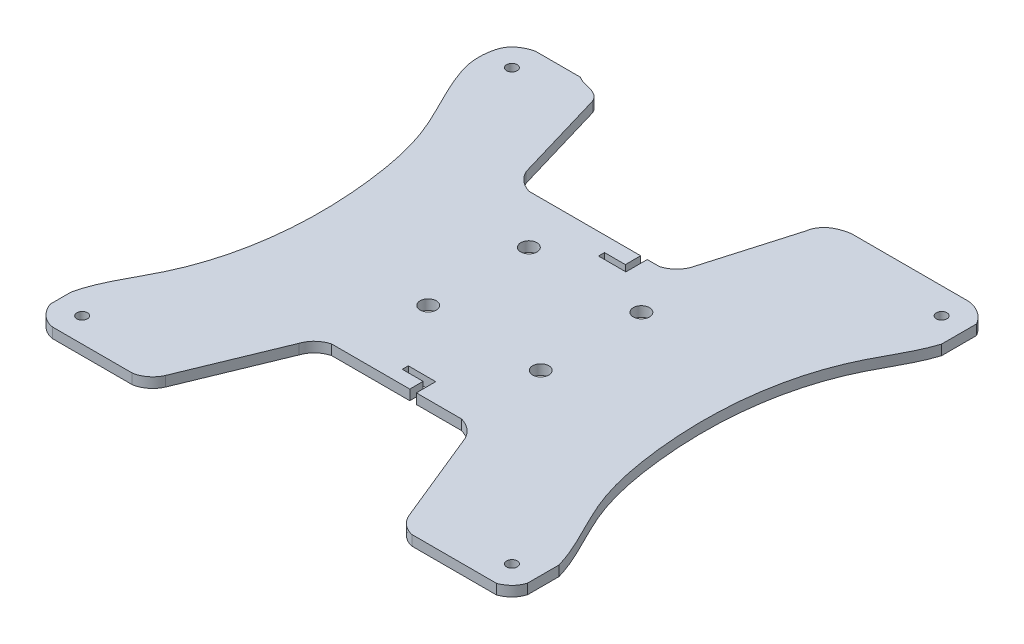
from build123d import *

# Parameters (mm, degrees)
SKETCH1_W           = 190000
SKETCH1_H           = 190000
BOSS_EXTRUDE1_DEPTH = 4000
SKETCH3_R           = 2100
SKETCH3_R_2         = 3200
CUT_EXTRUDE1_DEPTH  = 5000
CUT_EXTRUDE2_DEPTH  = 5000
CUT_EXTRUDE3_DEPTH  = 5000
CUT_EXTRUDE5_DEPTH  = 5000
CUT_EXTRUDE6_DEPTH  = 5000
CUT_EXTRUDE7_DEPTH  = 5000


with BuildPart() as part:
    # Sketch1 → Boss-Extrude1 (new body)
    with BuildSketch(Plane(origin=(0, 0, 0), x_dir=(1, 0, 0), z_dir=(0, 1, 0))):
        with Locations((210823.945907115, -88336.324664015)):
            Rectangle(SKETCH1_W, SKETCH1_H)
    extrude(amount=BOSS_EXTRUDE1_DEPTH)

    # Sketch3 → Cut-Extrude1 (cut)
    with BuildSketch(Plane(origin=(0, 4000, 0), x_dir=(1, 0, 0), z_dir=(0, 1, 0))):
        with Locations((126143.866924057, -173624.149677374)):
            Circle(SKETCH3_R)
        with Locations((126143.866924057, -3634.077007304)):
            Circle(SKETCH3_R)
        with Locations((296154.542680299, -3634.077007304)):
            Circle(SKETCH3_R)
        with Locations((296154.542680299, -173624.149677374)):
            Circle(SKETCH3_R)
        with Locations((191044.644572068, -101637.26269364)):
            Circle(SKETCH3_R_2)
        with Locations((235550.374690064, -101637.26269364)):
            Circle(SKETCH3_R_2)
        with Locations((235550.374690064, -61824.261196317)):
            Circle(SKETCH3_R_2)
        with Locations((191044.644572068, -61824.261196317)):
            Circle(SKETCH3_R_2)
    extrude(amount=-CUT_EXTRUDE1_DEPTH, mode=Mode.SUBTRACT)

    # Sketch5 → Cut-Extrude2 (cut)
    with BuildSketch(Plane(origin=(0, 4000, 0), x_dir=(1, 0, 0), z_dir=(0, 1, 0))):
        Polygon((207788.999633685, -48654.116334975), (216043.455607992, -48654.116334975), (216043.455607992, -37602.620851741), (218645.635527541, -37602.620851741), (218645.635527541, -48654.116334975), (218645.635527541, -51043.002818495), (207788.999633685, -51043.002818495), align=None)
        Polygon((207788.999633685, -126263.472912625), (218645.635527541, -126263.472912625), (218645.635527541, -128654.566221282), (218645.635527541, -138374.534898981), (216043.455607992, -138374.534898981), (216043.455607992, -128654.566221282), (207788.999633685, -128654.566221282), align=None)
    extrude(amount=-CUT_EXTRUDE2_DEPTH, mode=Mode.SUBTRACT)

    # Sketch6 → Cut-Extrude3 (cut)
    with BuildSketch(Plane(origin=(0, 4000, 0), x_dir=(1, 0, 0), z_dir=(0, 1, 0))):
        with BuildLine():
            Line((178471.820163171, -140109.359754133), (163071.170552362, -177534.564685488))
            add(Edge.make_bspline(
                [(155657.515385532, -183336.324664015), (157731.885377745, -183020.994179024), (160748.760085078, -181405.07530841), (162605.90754031, -178647.317923599), (163071.170552362, -177534.564685488)],
                knots=[0, 0, 0, 0, 0.634468693, 1, 1, 1, 1], degree=3))
            Line((155657.515385532, -183336.324664015), (266262.411359111, -183336.324664015))
            add(Edge.make_bspline(
                [(259266.078373493, -177534.564685488), (260561.872857841, -180397.751802051), (263152.589534383, -182680.185800011), (266262.411359111, -183336.324664015)],
                knots=[0, 0, 0, 0, 1, 1, 1, 1], degree=3))
            Line((259266.078373493, -177534.564685488), (243966.130587884, -140109.359754133))
            add(Edge.make_bspline(
                [(236550.462139666, -133936.024054895), (241651.051637241, -135449.012282161), (243966.130587884, -140109.359754133)],
                knots=[0, 0, 0, 1, 1, 1], degree=2))
            Line((236550.462139666, -133936.024054895), (185102.439988279, -133936.024054895))
            add(Edge.make_bspline(
                [(178471.820163171, -140109.359754133), (180186.635635182, -135422.197463971), (185102.439988279, -133936.024054895)],
                knots=[0, 0, 0, 1, 1, 1], degree=2))
        make_face()
    extrude(amount=-CUT_EXTRUDE3_DEPTH, mode=Mode.SUBTRACT)

    # Sketch8 → Cut-Extrude5 (cut)
    with BuildSketch(Plane(origin=(0, 4000, 0), x_dir=(1, 0, 0), z_dir=(0, 1, 0))):
        with BuildLine():
            Line((230043.291483907, -36422.519441484), (240185.730224741, -1546.039555534))
            add(Edge.make_bspline(
                [(240185.730224741, -1546.039555534), (240437.520308567, 680.278305544), (241984.621390825, 3139.280828934), (246534.93447169, 6145.656031903), (249963.241287316, 6629.200226119), (250330.131369908, 6663.675335985)],
                knots=[0, 0, 0, 0, 0.397894675, 0.502773588, 1, 1, 1, 1], degree=3))
            Line((250330.131369908, 6663.675335985), (140636.035759355, 10985.910589195))
            add(Edge.make_bspline(
                [(153591.447837824, 716.259412954), (151101.742170436, 7156.119382351), (141822.065236926, 2701.668088952), (140636.035759355, 10985.910589195)],
                knots=[0, 0, 0, 0, 1, 1, 1, 1], degree=3))
            Line((153591.447837824, 716.259412954), (164548.981059194, -36422.519441484))
            add(Edge.make_bspline(
                [(171964.649507412, -42595.855140723), (166864.060009837, -41082.866913457), (164548.981059194, -36422.519441484)],
                knots=[0, 0, 0, 1, 1, 1], degree=2))
            Line((171964.649507412, -42595.855140723), (223412.671658799, -42595.855140722))
            add(Edge.make_bspline(
                [(230043.291483907, -36422.519441484), (228328.476011896, -41109.681731646), (223412.671658799, -42595.855140722)],
                knots=[0, 0, 0, 1, 1, 1], degree=2))
        make_face()
    extrude(amount=-CUT_EXTRUDE5_DEPTH, mode=Mode.SUBTRACT)

    # Sketch10 → Cut-Extrude6 (cut)
    with BuildSketch(Plane(origin=(0, 4000, 0), x_dir=(1, 0, 0), z_dir=(0, 1, 0))):
        with BuildLine():
            Line((126568.265021739, -183336.324664015), (126568.265021739, -185665.609411408))
            Line((126568.265021739, -185665.609411408), (109180.234481187, -185665.609411408))
            Line((109180.234481187, -185665.609411408), (109180.234481187, 6663.675335982))
            Line((109180.234481187, 6663.675335982), (125030.1869172, 6663.675335982))
            add(Edge.make_bspline(
                [(125030.1869172, 6663.675335982), (122562.224098558, 5997.795768348), (117653.079744319, 3615.375092015), (115804.275384958, -3836.45056932), (115954.653061197, -10247.077165566), (120119.874839473, -23556.573512614), (131610.589150734, -41750.303858114), (136879.296883963, -68571.106279377), (138850.707053156, -102510.862237664), (132793.224720559, -136861.293815076), (117762.316535761, -158664.140308267), (115823.945907115, -167788.098096643)],
                knots=[0, 0, 0, 0, 0.043040905, 0.077979927, 0.116648398, 0.146192232, 0.301252258, 0.459464316, 0.579595031, 0.851431559, 1, 1, 1, 1], degree=3))
            add(Edge.make_bspline(
                [(115823.945907115, -167788.098096643), (112994.79052998, -174724.143024652), (118558.051378597, -184380.412782042), (126568.265021739, -183336.324664015)],
                knots=[0, 0, 0, 0, 1, 1, 1, 1], degree=3))
        make_face()
    extrude(amount=-CUT_EXTRUDE6_DEPTH, mode=Mode.SUBTRACT)

    # Sketch12 → Cut-Extrude7 (cut)
    with BuildSketch(Plane(origin=(0, 4000, 0), x_dir=(1, 0, 0), z_dir=(0, 1, 0))):
        with BuildLine():
            Line((296051.17429956, 6663.675335985), (296051.17429956, 8218.8565292))
            Line((296051.17429956, 8218.8565292), (313439.204840112, 8218.8565292))
            Line((313439.204840112, 8218.8565292), (313439.204840113, -184110.428218193))
            Line((313439.204840113, -184110.428218193), (297589.2524041, -184110.428218193))
            add(Edge.make_bspline(
                [(297589.2524041, -184110.428218193), (300057.21522274, -183444.548650555), (304966.359576981, -181062.127974224), (306815.163936342, -173610.302312887), (306664.786260102, -167199.675716641), (302499.564481827, -153890.179369594), (291008.850170566, -135696.449024094), (285740.142437337, -108875.646602831), (283768.732268143, -74935.890644544), (289826.21460074, -40585.459067132), (304857.122785538, -18782.61257394), (306795.493414184, -9658.654785565)],
                knots=[0, 0, 0, 0, 0.043040905, 0.077979927, 0.116648398, 0.146192232, 0.301252258, 0.459464316, 0.579595031, 0.851431559, 1, 1, 1, 1], degree=3))
            add(Edge.make_bspline(
                [(306795.493414184, -9658.654785565), (309763.173840221, -2284.482998838), (303711.424088356, 6332.787488571), (296051.17429956, 6663.675335985)],
                knots=[0, 0, 0, 0, 1, 1, 1, 1], degree=3))
        make_face()
    extrude(amount=-CUT_EXTRUDE7_DEPTH, mode=Mode.SUBTRACT)


solid = part.part
